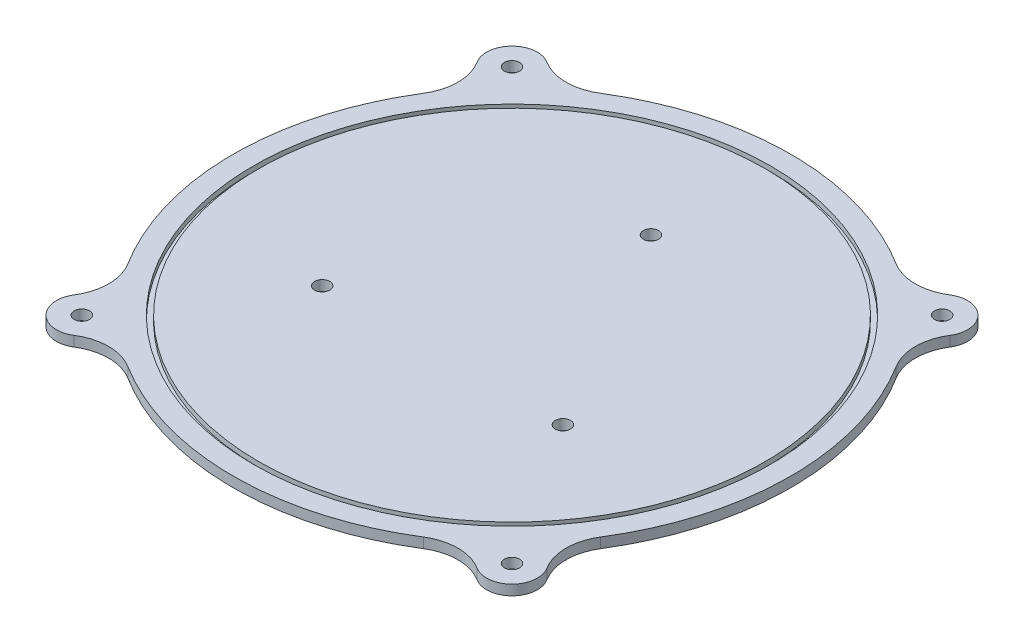
from build123d import *

# Parameters (mm, degrees)
SKETCH2_R           = 1.5
BOSS_EXTRUDE1_DEPTH = 2
SKETCH3_R           = 51
SKETCH3_R_2         = 50
CUT_EXTRUDE1_DEPTH  = 1


with BuildPart() as part:
    # Sketch2 → Boss-Extrude1 (new body)
    with BuildSketch(Plane(origin=(0, 0, 0), x_dir=(1, 0, 0), z_dir=(0, 1, 0))):
        with BuildLine():
            ThreePointArc((-46.644081999, 29.14326019), (-55, 0), (-46.644081999, -29.14326019))
            ThreePointArc((-46.644081999, -29.14326019), (-45.124834326, -34.456279799), (-46.659212641, -39.764949504))
            ThreePointArc((-46.659212641, -39.764949504), (-45.961940777, -45.961940777), (-39.764949504, -46.659212641))
            ThreePointArc((-39.764949504, -46.659212641), (-34.456279799, -45.124834326), (-29.14326019, -46.644081999))
            ThreePointArc((-29.14326019, -46.644081999), (0, -55), (29.14326019, -46.644081999))
            ThreePointArc((29.14326019, -46.644081999), (34.456279799, -45.124834326), (39.764949504, -46.659212641))
            ThreePointArc((39.764949504, -46.659212641), (45.961940777, -45.961940777), (46.659212641, -39.764949504))
            ThreePointArc((46.659212641, -39.764949504), (45.124834326, -34.456279799), (46.644081999, -29.14326019))
            ThreePointArc((46.644081999, -29.14326019), (55, 0), (46.644081999, 29.14326019))
            ThreePointArc((46.644081999, 29.14326019), (45.124834326, 34.456279799), (46.659212641, 39.764949504))
            ThreePointArc((46.659212641, 39.764949504), (45.961940777, 45.961940777), (39.764949504, 46.659212641))
            ThreePointArc((39.764949504, 46.659212641), (34.456279799, 45.124834326), (29.14326019, 46.644081999))
            ThreePointArc((29.14326019, 46.644081999), (0, 55), (-29.14326019, 46.644081999))
            ThreePointArc((-29.14326019, 46.644081999), (-34.456279799, 45.124834326), (-39.764949504, 46.659212641))
            ThreePointArc((-39.764949504, 46.659212641), (-45.961940777, 45.961940777), (-46.659212641, 39.764949504))
            ThreePointArc((-46.659212641, 39.764949504), (-45.124834326, 34.456279799), (-46.644081999, 29.14326019))
        make_face()
        with Locations((-42.426406871, 42.426406871)):
            Circle(SKETCH2_R, mode=Mode.SUBTRACT)
        with Locations((-23.741169162, -13.706970407)):
            Circle(SKETCH2_R, mode=Mode.SUBTRACT)
        with Locations((23.741169162, -13.706970407)):
            Circle(SKETCH2_R, mode=Mode.SUBTRACT)
        with Locations((0, 27.413940814)):
            Circle(SKETCH2_R, mode=Mode.SUBTRACT)
        with Locations((42.426406871, 42.426406871)):
            Circle(SKETCH2_R, mode=Mode.SUBTRACT)
        with Locations((42.426406871, -42.426406871)):
            Circle(SKETCH2_R, mode=Mode.SUBTRACT)
        with Locations((-42.426406871, -42.426406871)):
            Circle(SKETCH2_R, mode=Mode.SUBTRACT)
    extrude(amount=BOSS_EXTRUDE1_DEPTH)

    # Sketch3 → Cut-Extrude1 (cut)
    with BuildSketch(Plane(origin=(0, 2, 0), x_dir=(1, 0, 0), z_dir=(0, 1, 0))):
        Circle(SKETCH3_R)
        Circle(SKETCH3_R_2, mode=Mode.SUBTRACT)
    extrude(amount=-CUT_EXTRUDE1_DEPTH, mode=Mode.SUBTRACT)


solid = part.part
